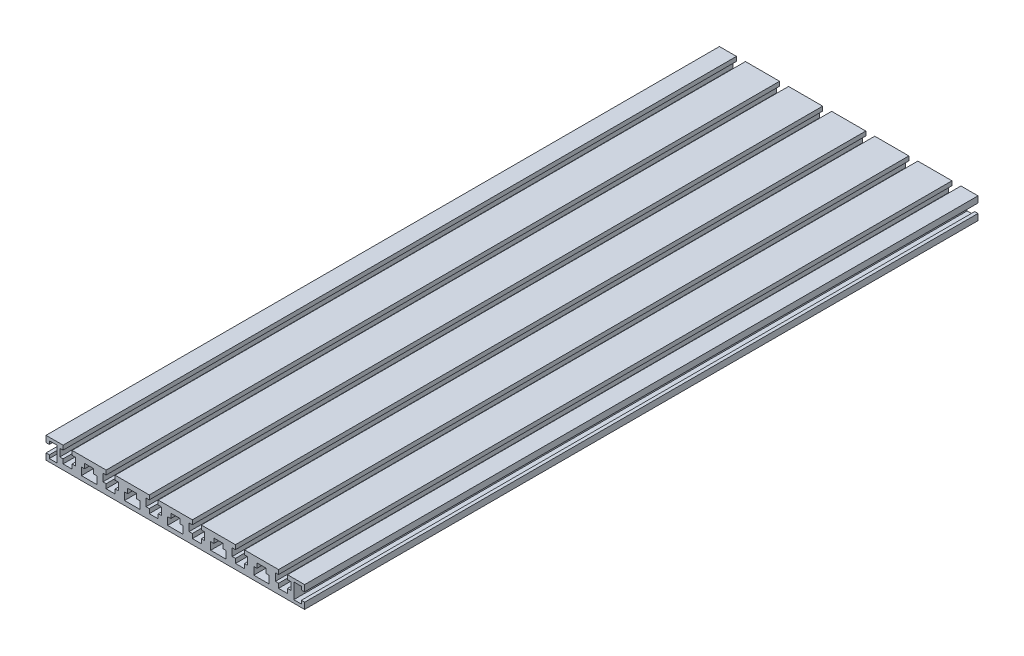
from build123d import *

# Parameters (mm, degrees)
BOSS_EXTRUDE1_DEPTH = 625


with BuildPart() as part:
    # Sketch1 → Boss-Extrude1 (new body)
    with BuildSketch(Plane.XY):
        Polygon((-120, 10), (-120, 4.166666667), (-116.945068586, 4.166666667), (-116.945068586, 7.166666667), (-109.945068586, 7.166666667), (-109.945068586, -7.166666667), (-116.945068586, -7.166666667), (-116.945068586, -4.166666667), (-120, -4.166666667), (-120, -10), (120, -10), (120, -4.166666667), (116.945068586, -4.166666667), (116.945068586, -7.166666667), (109.945068586, -7.166666667), (109.945068586, 7.166666667), (116.945068586, 7.166666667), (116.945068586, 4.166666667), (120, 4.166666667), (120, 10), (104.166666667, 10), (104.166666667, 6), (107.166666667, 6), (107.166666667, -1), (104.166666667, -1), (104.166666667, -5.093909387), (95.833333333, -5.093909387), (95.833333333, -1), (92.833333333, -1), (92.833333333, 6), (95.833333333, 6), (95.833333333, 10), (64.166666667, 10), (64.166666667, 6), (67.166666667, 6), (67.166666667, -1), (64.166666667, -1), (64.166666667, -5.093909387), (55.833333333, -5.093909387), (55.833333333, -1), (52.833333333, -1), (52.833333333, 6), (55.833333333, 6), (55.833333333, 10), (24.166666667, 10), (24.166666667, 6), (27.166666667, 6), (27.166666667, -1), (24.166666667, -1), (24.166666667, -5.093909387), (15.833333333, -5.093909387), (15.833333333, -1), (12.833333333, -1), (12.833333333, 6), (15.833333333, 6), (15.833333333, 10), (-15.833333333, 10), (-15.833333333, 6), (-12.833333333, 6), (-12.833333333, -1), (-15.833333333, -1), (-15.833333333, -5.093909387), (-24.166666667, -5.093909387), (-24.166666667, -1), (-27.166666667, -1), (-27.166666667, 6), (-24.166666667, 6), (-24.166666667, 10), (-55.833333333, 10), (-55.833333333, 6), (-52.833333333, 6), (-52.833333333, -1), (-55.833333333, -1), (-55.833333333, -5.093909387), (-64.166666667, -5.093909387), (-64.166666667, -1), (-67.166666667, -1), (-67.166666667, 6), (-64.166666667, 6), (-64.166666667, 10), (-95.833333333, 10), (-95.833333333, 6), (-92.833333333, 6), (-92.833333333, -1), (-95.833333333, -1), (-95.833333333, -5.093909387), (-104.166666667, -5.093909387), (-104.166666667, -1), (-107.166666667, -1), (-107.166666667, 6), (-104.166666667, 6), (-104.166666667, 10), align=None)
        Polygon((-72.833333333, -6), (-87.166666667, -6), (-87.166666667, 1), (-84.166666667, 1), (-84.166666667, 5.362249924), (-75.833333333, 5.362249924), (-75.833333333, 1), (-72.833333333, 1), align=None, mode=Mode.SUBTRACT)
        Polygon((-32.833333333, -6), (-47.166666667, -6), (-47.166666667, 1), (-44.166666667, 1), (-44.166666667, 5.362249924), (-35.833333333, 5.362249924), (-35.833333333, 1), (-32.833333333, 1), align=None, mode=Mode.SUBTRACT)
        Polygon((7.166666667, -6), (-7.166666667, -6), (-7.166666667, 1), (-4.166666667, 1), (-4.166666667, 5.362249924), (4.166666667, 5.362249924), (4.166666667, 1), (7.166666667, 1), align=None, mode=Mode.SUBTRACT)
        Polygon((47.166666667, -6), (32.833333333, -6), (32.833333333, 1), (35.833333333, 1), (35.833333333, 5.362249924), (44.166666667, 5.362249924), (44.166666667, 1), (47.166666667, 1), align=None, mode=Mode.SUBTRACT)
        Polygon((87.166666667, -6), (72.833333333, -6), (72.833333333, 1), (75.833333333, 1), (75.833333333, 5.362249924), (84.166666667, 5.362249924), (84.166666667, 1), (87.166666667, 1), align=None, mode=Mode.SUBTRACT)
    extrude(amount=BOSS_EXTRUDE1_DEPTH)


solid = part.part
